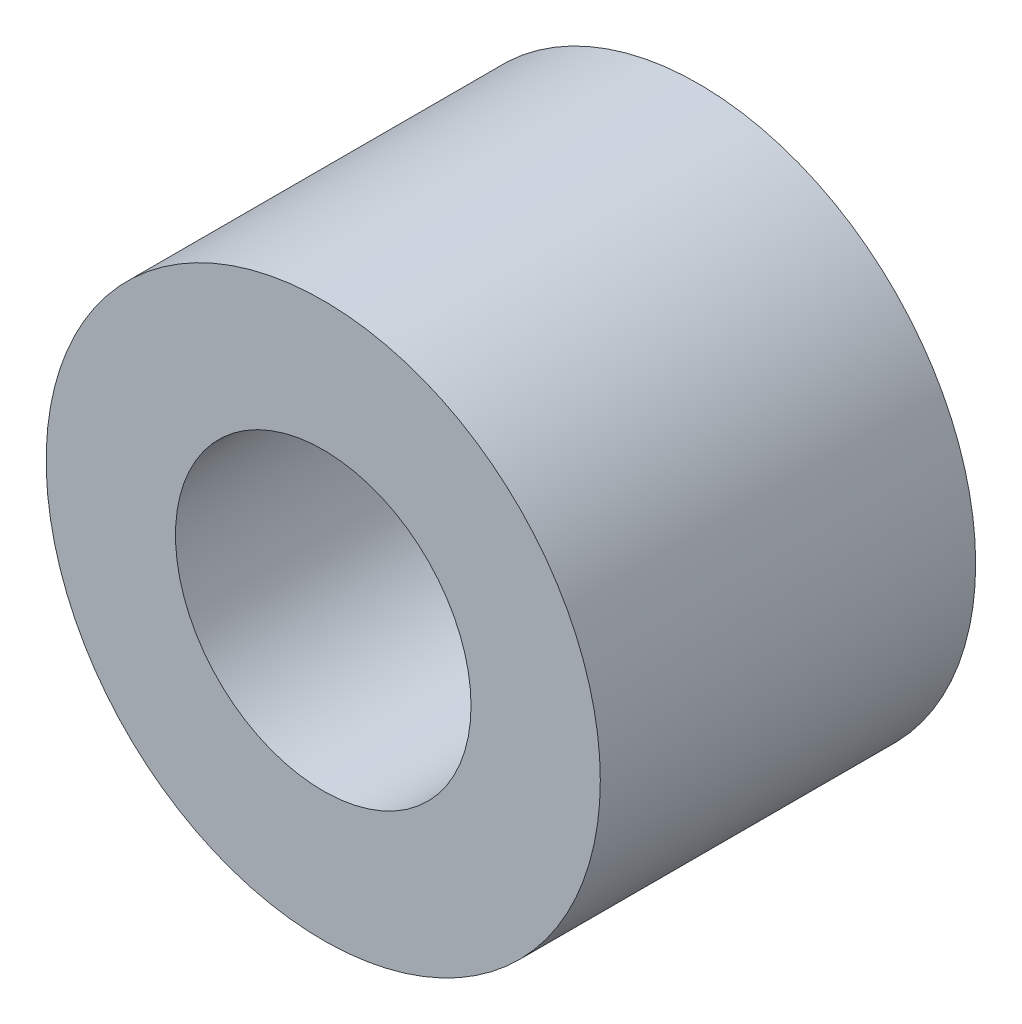
from build123d import *

# Parameters (mm, degrees)
SKETCH1_R           = 3.75
SKETCH1_R_2         = 2
BOSS_EXTRUDE1_DEPTH = 5.08


with BuildPart() as part:
    # Sketch1 → Boss-Extrude1 (new body)
    with BuildSketch(Plane.XY):
        Circle(SKETCH1_R)
        Circle(SKETCH1_R_2, mode=Mode.SUBTRACT)
    extrude(amount=BOSS_EXTRUDE1_DEPTH)


solid = part.part
